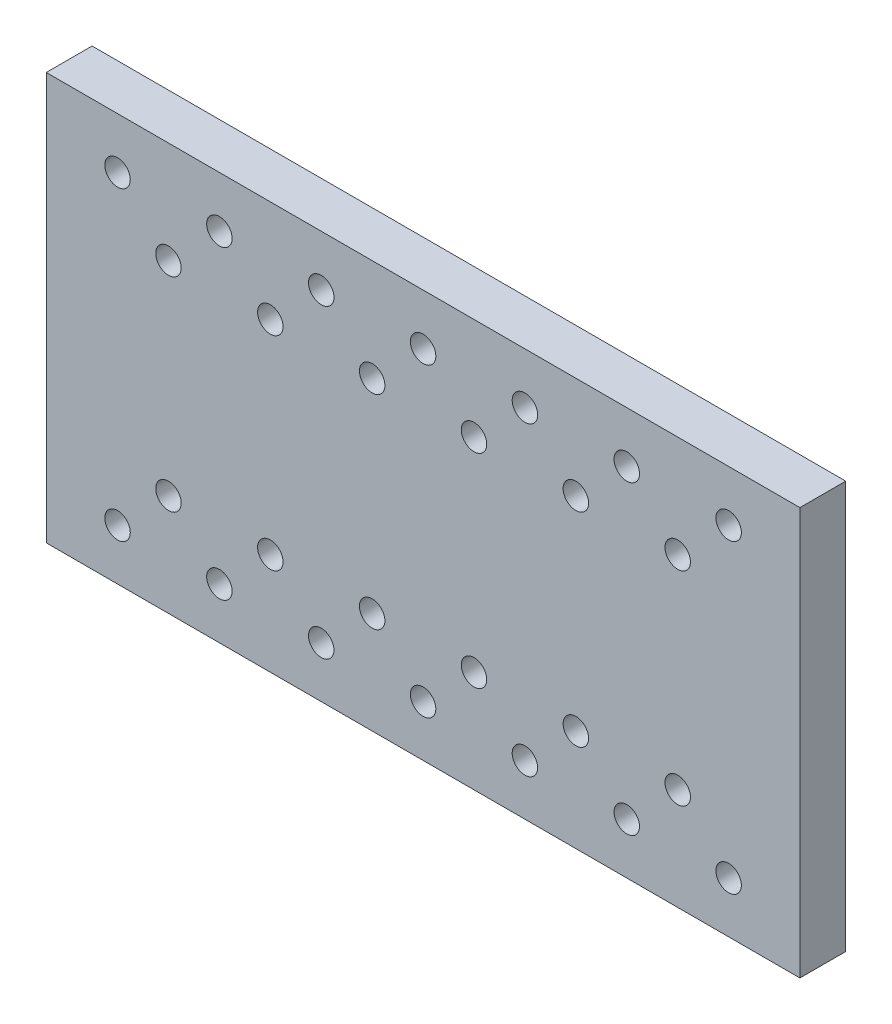
from build123d import *

# Parameters (mm, degrees)
SKETCH1_W           = 187.96
SKETCH1_H           = 101.6
SKETCH1_R           = 3.175
BOSS_EXTRUDE1_DEPTH = 11.43


with BuildPart() as part:
    # Sketch1 → Boss-Extrude1 (new body)
    with BuildSketch(Plane.XY):
        with Locations((-93.98, 50.8)):
            Rectangle(SKETCH1_W, SKETCH1_H)
        with Locations((-17.78, 88.9)):
            Circle(SKETCH1_R, mode=Mode.SUBTRACT)
        with Locations((-17.78, 12.7)):
            Circle(SKETCH1_R, mode=Mode.SUBTRACT)
        with Locations((-43.18, 12.7)):
            Circle(SKETCH1_R, mode=Mode.SUBTRACT)
        with Locations((-43.18, 88.9)):
            Circle(SKETCH1_R, mode=Mode.SUBTRACT)
        with Locations((-170.18, 88.9)):
            Circle(SKETCH1_R, mode=Mode.SUBTRACT)
        with Locations((-170.18, 12.7)):
            Circle(SKETCH1_R, mode=Mode.SUBTRACT)
        with Locations((-144.78, 12.7)):
            Circle(SKETCH1_R, mode=Mode.SUBTRACT)
        with Locations((-144.78, 88.9)):
            Circle(SKETCH1_R, mode=Mode.SUBTRACT)
        with Locations((-119.38, 88.9)):
            Circle(SKETCH1_R, mode=Mode.SUBTRACT)
        with Locations((-68.58, 88.9)):
            Circle(SKETCH1_R, mode=Mode.SUBTRACT)
        with Locations((-119.38, 12.7)):
            Circle(SKETCH1_R, mode=Mode.SUBTRACT)
        with Locations((-68.58, 12.7)):
            Circle(SKETCH1_R, mode=Mode.SUBTRACT)
        with Locations((-93.98, 88.9)):
            Circle(SKETCH1_R, mode=Mode.SUBTRACT)
        with Locations((-93.98, 12.7)):
            Circle(SKETCH1_R, mode=Mode.SUBTRACT)
        with Locations((-106.68, 76.2)):
            Circle(SKETCH1_R, mode=Mode.SUBTRACT)
        with Locations((-132.08, 76.2)):
            Circle(SKETCH1_R, mode=Mode.SUBTRACT)
        with Locations((-157.48, 76.2)):
            Circle(SKETCH1_R, mode=Mode.SUBTRACT)
        with Locations((-106.68, 25.4)):
            Circle(SKETCH1_R, mode=Mode.SUBTRACT)
        with Locations((-132.08, 25.4)):
            Circle(SKETCH1_R, mode=Mode.SUBTRACT)
        with Locations((-157.48, 25.4)):
            Circle(SKETCH1_R, mode=Mode.SUBTRACT)
        with Locations((-81.28, 76.2)):
            Circle(SKETCH1_R, mode=Mode.SUBTRACT)
        with Locations((-55.88, 76.2)):
            Circle(SKETCH1_R, mode=Mode.SUBTRACT)
        with Locations((-30.48, 76.2)):
            Circle(SKETCH1_R, mode=Mode.SUBTRACT)
        with Locations((-81.28, 25.4)):
            Circle(SKETCH1_R, mode=Mode.SUBTRACT)
        with Locations((-55.88, 25.4)):
            Circle(SKETCH1_R, mode=Mode.SUBTRACT)
        with Locations((-30.48, 25.4)):
            Circle(SKETCH1_R, mode=Mode.SUBTRACT)
    extrude(amount=BOSS_EXTRUDE1_DEPTH)


solid = part.part
